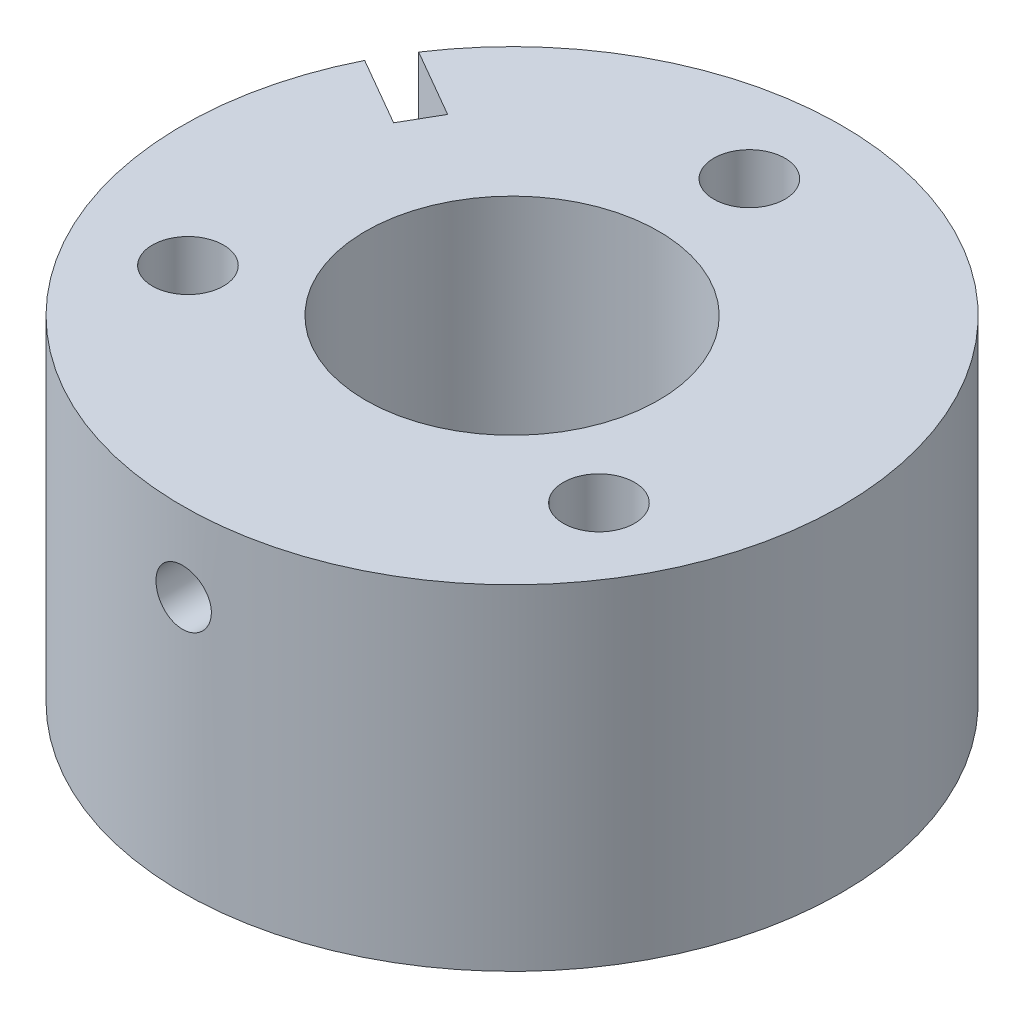
from build123d import *

# Parameters (mm, degrees)
SKETCH1_R                  = 11.1125
SKETCH1_R_2                = 2.7
BOSS_EXTRUDE1_DEPTH        = 12.7
M5X0_8_TAPPED_HOLE1_REACH  = 61.172
M5X0_8_TAPPED_HOLE1_BORE_R = 2.1


with BuildPart() as part:
    # Sketch1 → Boss-Extrude1 (new, symmetric)
    with BuildSketch(Plane(origin=(0, 0, 0), x_dir=(1, 0, 0), z_dir=(0, 1, 0))):
        with BuildLine():
            Line((-15.665476391, 10.776517819), (-20.861628814, 13.776517819))
            ThreePointArc((-20.861628814, 13.776517819), (21.650635095, -12.5), (-22.361628814, 11.178441608))
            Line((-22.361628814, 11.178441608), (-17.165476391, 8.178441608))
            Line((-17.165476391, 8.178441608), (-15.665476391, 10.776517819))
        make_face()
        with Locations(Location((0, 0, 0), (0, 0, 270))):
            Circle(SKETCH1_R, mode=Mode.SUBTRACT)
        with Locations(Location((0, 18, 0), (0, 0, 270))):
            Circle(SKETCH1_R_2, mode=Mode.SUBTRACT)
        with Locations(Location((15.588457268, -9, 0), (0, 0, 270))):
            Circle(SKETCH1_R_2, mode=Mode.SUBTRACT)
        with Locations(Location((-15.588457268, -9, 0), (0, 0, 270))):
            Circle(SKETCH1_R_2, mode=Mode.SUBTRACT)
    extrude(amount=BOSS_EXTRUDE1_DEPTH, both=True)

    # M5x0.8 Tapped Hole1 bore (on position points) → M5x0.8 Tapped Hole1 (cut, up to next)
    with BuildSketch(Plane(origin=(0, 6.7, 25), x_dir=(1, 0, 0), z_dir=(0, 0, 1)), mode=Mode.PRIVATE) as m5x0_8_tapped_hole1_sk1:
        Circle(M5X0_8_TAPPED_HOLE1_BORE_R)
    m5x0_8_tapped_hole1_tool1 = extrude(m5x0_8_tapped_hole1_sk1.sketch, amount=-M5X0_8_TAPPED_HOLE1_REACH, mode=Mode.PRIVATE) & part.part
    add(m5x0_8_tapped_hole1_tool1.solids().sort_by_distance((0, 6.7, 25))[0], mode=Mode.SUBTRACT)


solid = part.part
